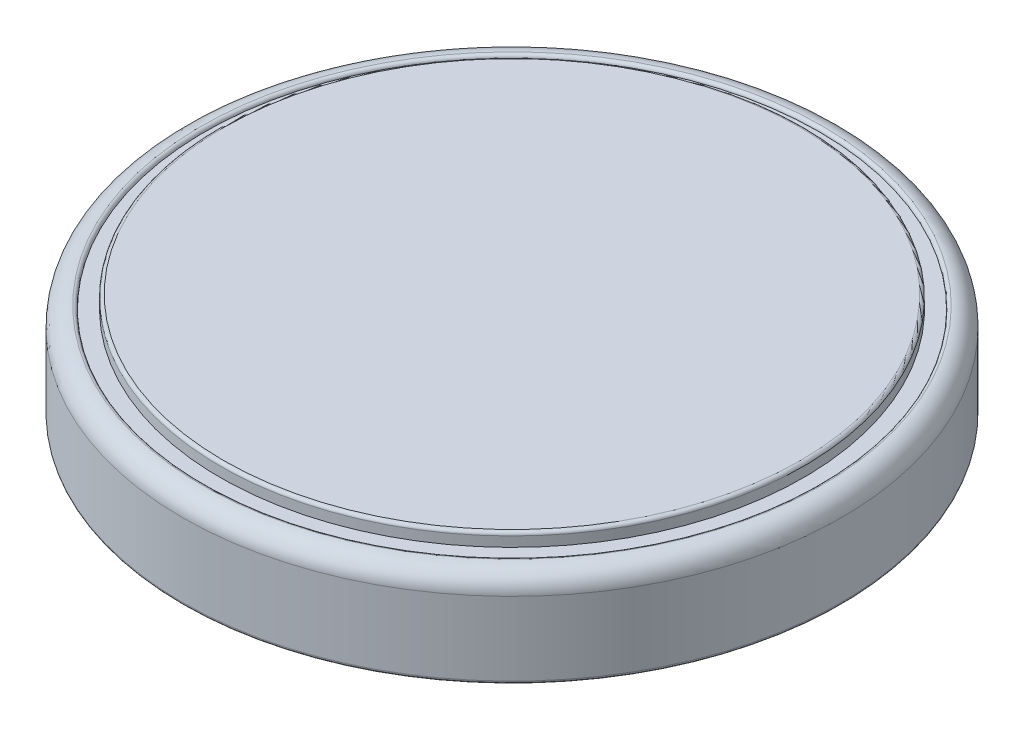
from build123d import *

# Parameters (mm, degrees)
FILLET1_R = 0.1


with BuildPart() as part:
    # Sketch1 → Revolve1 (revolve)
    with BuildSketch(Plane.XY):
        with BuildLine():
            Line((0, 0), (10, 0))
            Line((10, 0), (10, 2.325))
            ThreePointArc((10, 2.325), (9.831586399, 2.731586399), (9.425, 2.9))
            ThreePointArc((9.425, 2.9), (9.354289322, 2.870710678), (9.325, 2.8))
            Line((9.325, 2.8), (8.85, 2.8))
            Line((8.85, 2.8), (8.85, 3.1))
            ThreePointArc((8.85, 3.1), (8.820710678, 3.170710678), (8.75, 3.2))
            Line((8.75, 3.2), (0, 3.2))
            Line((0, 3.2), (0, 0))
        make_face()
    revolve(axis=Axis((0, 0, 0), (0, 1, 0)))

    # Fillet1
    fillet1_edges = [part.edges().sort_by_distance(p)[0] for p in [
        (-10, 0, 0),
    ]]
    fillet(fillet1_edges, radius=FILLET1_R)


solid = part.part
